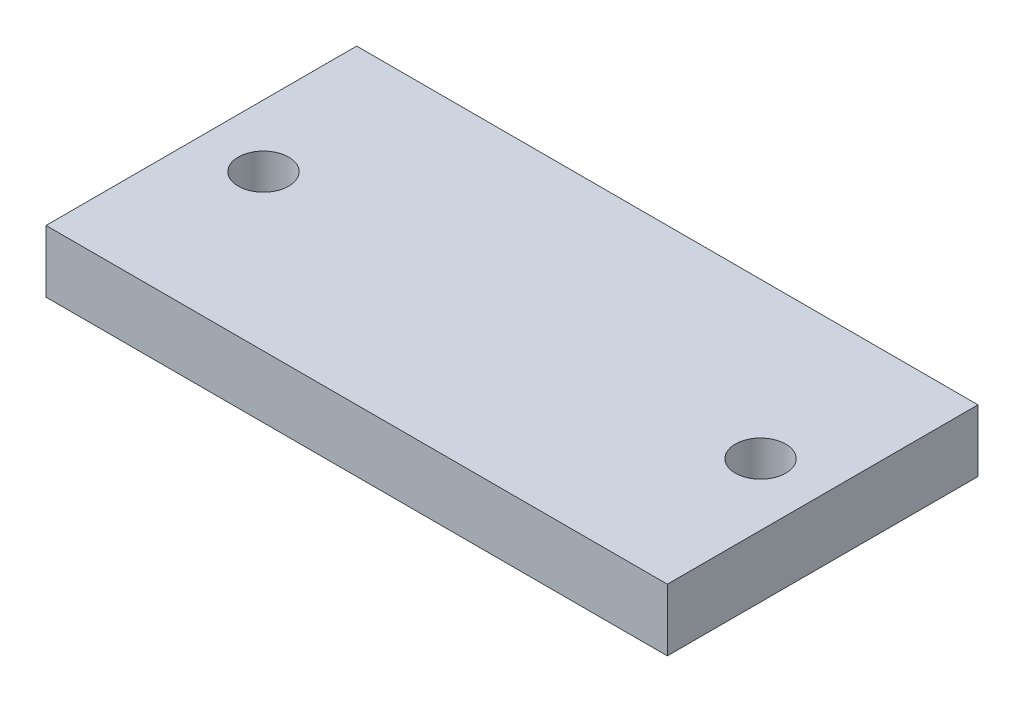
from build123d import *

# Parameters (mm, degrees)
SKETCH1_W           = 254
SKETCH1_H           = 127
SKETCH1_R           = 10.31875
BOSS_EXTRUDE1_DEPTH = 25.4


with BuildPart() as part:
    # Sketch1 → Boss-Extrude1 (new body)
    with BuildSketch(Plane(origin=(0, 0, 0), x_dir=(1, 0, 0), z_dir=(0, 1, 0))):
        with Locations((127, 63.5)):
            Rectangle(SKETCH1_W, SKETCH1_H)
        with Locations((25.4, 63.5)):
            Circle(SKETCH1_R, mode=Mode.SUBTRACT)
        with Locations((228.6, 63.5)):
            Circle(SKETCH1_R, mode=Mode.SUBTRACT)
    extrude(amount=BOSS_EXTRUDE1_DEPTH)


solid = part.part
